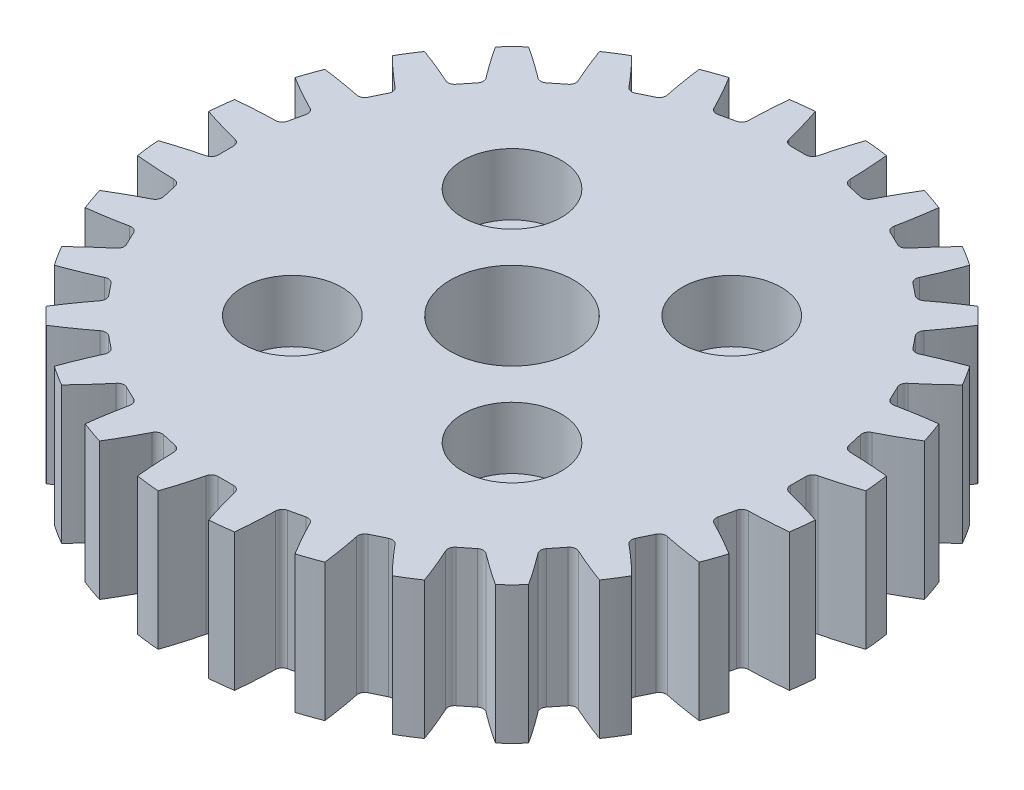
from build123d import *

# Parameters (mm, degrees)
SKETCH1_R           = 24
SKETCH1_R_2         = 4.5
SKETCH1_R_3         = 2.1
BOSS_EXTRUDE1_DEPTH = 10
CUT_EXTRUDE1_DEPTH  = 11
CIRPATTERN1_COUNT   = 28
SKETCH3_R           = 3.6
CUT_EXTRUDE2_DEPTH  = 4.5


with BuildPart() as part:
    # Sketch1 → Boss-Extrude1 (new body)
    with BuildSketch(Plane(origin=(0, 0, 0), x_dir=(1, 0, 0), z_dir=(0, 1, 0))):
        Circle(SKETCH1_R)
        Circle(SKETCH1_R_2, mode=Mode.SUBTRACT)
        with Locations((-8, 8)):
            Circle(SKETCH1_R_3, mode=Mode.SUBTRACT)
        with Locations((8, 8)):
            Circle(SKETCH1_R_3, mode=Mode.SUBTRACT)
        with Locations((8, -8)):
            Circle(SKETCH1_R_3, mode=Mode.SUBTRACT)
        with Locations((-8, -8)):
            Circle(SKETCH1_R_3, mode=Mode.SUBTRACT)
    extrude(amount=BOSS_EXTRUDE1_DEPTH)

    # Sketch2 → Cut-Extrude1 (cut, through all)
    with BuildSketch(Plane(origin=(0, 10, 0), x_dir=(1, 0, 0), z_dir=(0, 1, 0))):
        with BuildLine():
            ThreePointArc((-1.05, 21.240501256), (-0.876425843, 20.952863479), (-0.56, 20.84))
            Line((-0.56, 20.84), (0, 20.84))
            Line((0, 20.84), (0.56, 20.84))
            ThreePointArc((0.56, 20.84), (0.876425843, 20.952863479), (1.05, 21.240501256))
            ThreePointArc((1.05, 21.240501256), (1.418076465, 22.592842246), (1.84, 23.929362716))
            ThreePointArc((1.84, 23.929362716), (0, 24), (-1.84, 23.929362716))
            ThreePointArc((-1.84, 23.929362716), (-1.418076465, 22.592842246), (-1.05, 21.240501256))
        make_face()
    cut_extrude1 = extrude(amount=-CUT_EXTRUDE1_DEPTH, mode=Mode.SUBTRACT)

    # CirPattern1: Cut-Extrude1 ×28 about axis
    cirpattern1_axis = Axis((0, 0, 0), (0, 1, 0))
    for i in range(1, CIRPATTERN1_COUNT):
        add(cut_extrude1.rotate(cirpattern1_axis, i * 360 / CIRPATTERN1_COUNT), mode=Mode.SUBTRACT)

    # Sketch3 → Cut-Extrude2 (cut)
    with BuildSketch(Plane(origin=(0, 10, 0), x_dir=(1, 0, 0), z_dir=(0, 1, 0))):
        with Locations((-8, 8)):
            Circle(SKETCH3_R)
        with Locations((8, 8)):
            Circle(SKETCH3_R)
        with Locations((8, -8)):
            Circle(SKETCH3_R)
        with Locations((-8, -8)):
            Circle(SKETCH3_R)
    extrude(amount=-CUT_EXTRUDE2_DEPTH, mode=Mode.SUBTRACT)


solid = part.part
